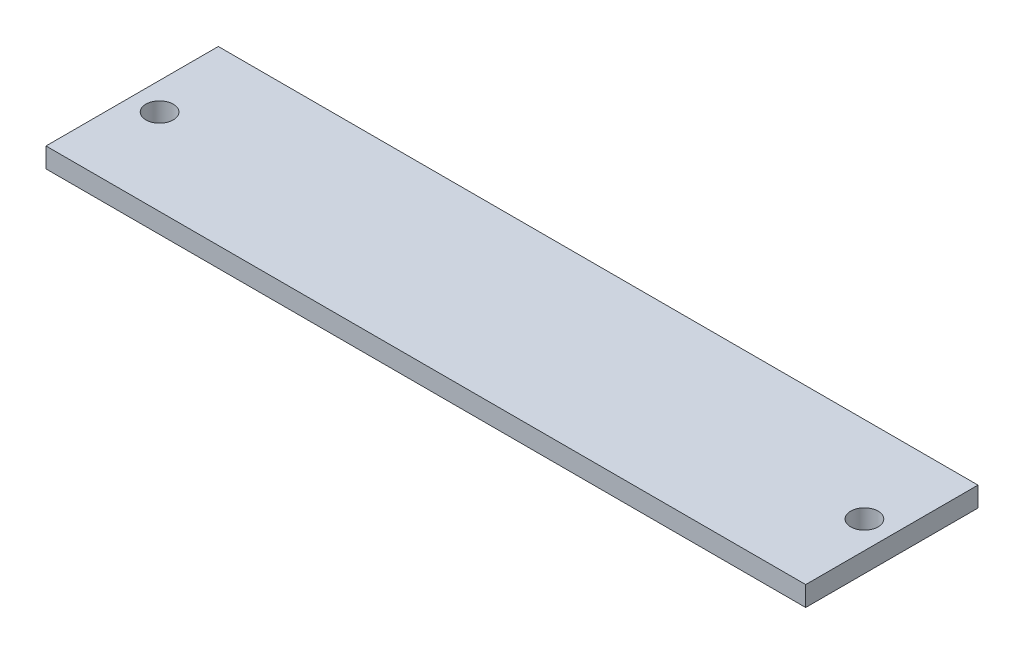
from build123d import *

# Parameters (mm, degrees)
SKETCH2_W           = 97
SKETCH2_H           = 22
SKETCH2_R           = 1.75
BOSS_EXTRUDE1_DEPTH = 2.54


with BuildPart() as part:
    # Sketch2 → Boss-Extrude1 (new body)
    with BuildSketch(Plane(origin=(0, 0, 0), x_dir=(1, 0, 0), z_dir=(0, 1, 0))):
        Rectangle(SKETCH2_W, SKETCH2_H)
        with Locations((45, 0)):
            Circle(SKETCH2_R, mode=Mode.SUBTRACT)
        with Locations((-45, 0)):
            Circle(SKETCH2_R, mode=Mode.SUBTRACT)
    extrude(amount=BOSS_EXTRUDE1_DEPTH)


solid = part.part
